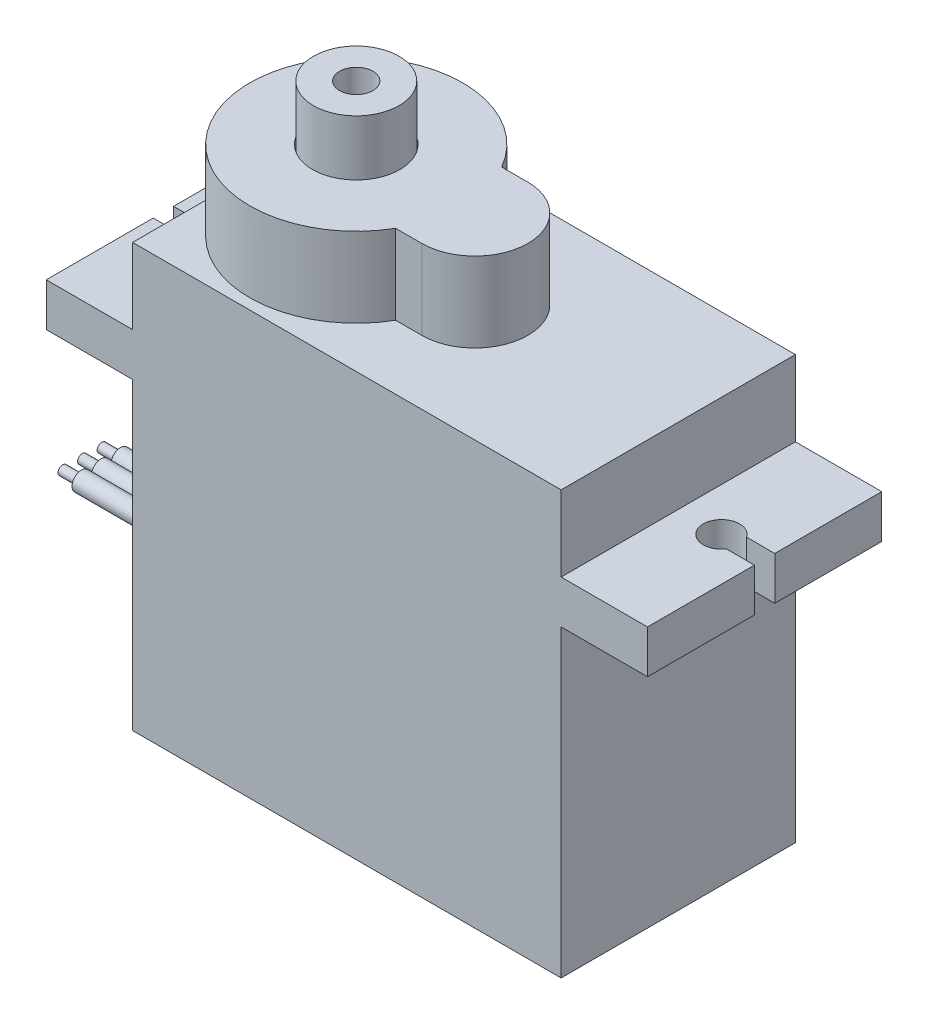
from build123d import *

# Parameters (mm, degrees)
BOSS_EXTRUDE1_DEPTH      = 6.295
BOSS_EXTRUDE2_DEPTH      = 4.28
SKETCH4_R                = 0.975
SKETCH4_W                = 1.511544683
SKETCH4_H                = 1.09
CUT_EXTRUDE1_DEPTH       = 27.991002668
SKETCH5_R                = 1
SKETCH5_R_2              = 0.975
CUT_EXTRUDE2_DEPTH       = 1
SKETCH6_R                = 0.5
BOSS_EXTRUDE4_DEPTH      = 8
SKETCH7_R                = 0.25
BOSS_EXTRUDE5_DEPTH      = 1
FILLET1_R                = 0.3
BOSS_EXTRUDE6_DEPTH      = 2.95
BOSS_EXTRUDE6_DEPTH_BACK = 1
SKETCH12_R               = 2.3
SKETCH12_R_2             = 0.9
SKETCH13_R               = 2.35
CUT_EXTRUDE5_DEPTH       = 5


with BuildPart() as part:
    # Sketch1 → Boss-Extrude1 (new, symmetric)
    with BuildSketch(Plane.XY):
        Polygon((-7.13, 6.38), (15.9, 6.38), (15.9, 2.32), (20.54, 2.32), (20.54, 0), (15.9, 0), (15.9, -16.34), (-7.13, -16.34), (-7.13, 0), (-11.77, 0), (-11.77, 2.32), (-7.13, 2.32), align=None)
    extrude(amount=BOSS_EXTRUDE1_DEPTH, both=True)

    # Sketch2 → Boss-Extrude2 (add)
    with BuildSketch(Plane(origin=(0, 6.38, 0), x_dir=(1, 0, 0), z_dir=(0, 1, 0))):
        with BuildLine():
            Line((3.560191336, -2.85), (4.97, -2.85))
            ThreePointArc((4.97, -2.85), (7.82, 0), (4.97, 2.85))
            Line((4.97, 2.85), (3.560191336, 2.85))
            ThreePointArc((3.560191336, 2.85), (-7.13, 0), (3.560191336, -2.85))
        make_face()
    extrude(amount=BOSS_EXTRUDE2_DEPTH)

    # Sketch4 → Cut-Extrude1 (cut, through all)
    with BuildSketch(Plane(origin=(0, 0, 0), x_dir=(1, 0, 0), z_dir=(0, 1, 0))):
        with Locations((-9.45, 0)):
            Circle(SKETCH4_R)
        with Locations((-11.014227659, 0)):
            Rectangle(SKETCH4_W, SKETCH4_H)
    cut_extrude1 = extrude(amount=CUT_EXTRUDE1_DEPTH, mode=Mode.SUBTRACT)

    # Sketch5 → Cut-Extrude2 (cut)
    # profile 1 of 4: a face of its own
    with BuildSketch(Plane.XZ.offset(16.34)):
        with Locations((-5.49, 4.35)):
            Circle(SKETCH5_R)
        with Locations((-5.49, 4.35)):
            Circle(SKETCH5_R_2, mode=Mode.SUBTRACT)
    # profile 2 of 4: a face of its own
    with BuildSketch(Plane.XZ.offset(16.34)):
        with Locations((-5.49, -4.35)):
            Circle(SKETCH5_R)
        with Locations((-5.49, -4.35)):
            Circle(SKETCH5_R_2, mode=Mode.SUBTRACT)
    # profile 3 of 4: a face of its own
    with BuildSketch(Plane.XZ.offset(16.34)):
        with Locations((14.26, -4.35)):
            Circle(SKETCH5_R)
        with Locations((14.26, -4.35)):
            Circle(SKETCH5_R_2, mode=Mode.SUBTRACT)
    # profile 4 of 4: a face of its own
    with BuildSketch(Plane.XZ.offset(16.34)):
        with Locations((14.26, 4.35)):
            Circle(SKETCH5_R)
        with Locations((14.26, 4.35)):
            Circle(SKETCH5_R_2, mode=Mode.SUBTRACT)
    extrude(amount=-CUT_EXTRUDE2_DEPTH, mode=Mode.SUBTRACT)

    # Sketch6 → Boss-Extrude4 (add)
    with BuildSketch(Plane.ZY.offset(7.13)):
        with Locations((0, -11.34)):
            Circle(SKETCH6_R)
        with Locations((1.05, -11.34)):
            Circle(SKETCH6_R)
        with Locations((-1.05, -11.34)):
            Circle(SKETCH6_R)
    extrude(amount=BOSS_EXTRUDE4_DEPTH)

    # Sketch7 → Boss-Extrude5 (add)
    with BuildSketch(Plane.ZY.offset(15.13)):
        with Locations((0, -11.34)):
            Circle(SKETCH7_R)
        with Locations((1.05, -11.34)):
            Circle(SKETCH7_R)
        with Locations((-1.05, -11.34)):
            Circle(SKETCH7_R)
    extrude(amount=BOSS_EXTRUDE5_DEPTH)

    # Fillet1
    fillet1_edges = [part.edges().sort_by_distance(p)[0] for p in [
        (13.285, -16.34, -4.35),
        (13.285, -16.34, 4.35),
        (-6.465, -16.34, -4.35),
        (-6.465, -16.34, 4.35),
    ]]
    fillet(fillet1_edges, radius=FILLET1_R)

    # Sketch13 → Cut-Extrude5 (cut)
    with BuildSketch(Plane(origin=(0, 13.61, 0), x_dir=(1, 0, 0), z_dir=(0, 1, 0))):
        with Locations((-1.405, 0)):
            Circle(SKETCH13_R)
    extrude(amount=-CUT_EXTRUDE5_DEPTH, mode=Mode.SUBTRACT)

    # Symétrie1: Cut-Extrude1 across plane
    add(cut_extrude1.mirror(Plane.ZY.offset(-4.385)), mode=Mode.SUBTRACT)


with BuildPart() as body_2:
    # Sketch12 → Boss-Extrude6 (new, two sides: drawn at the far end of the back side and taken through both)
    with BuildSketch(Plane(origin=(0, 10.66, 0), x_dir=(1, 0, 0), z_dir=(0, 1, 0)).offset(-BOSS_EXTRUDE6_DEPTH_BACK)):
        with Locations((-1.405, 0)):
            Circle(SKETCH12_R)
        with Locations((-1.405, 0)):
            Circle(SKETCH12_R_2, mode=Mode.SUBTRACT)
    extrude(amount=BOSS_EXTRUDE6_DEPTH + BOSS_EXTRUDE6_DEPTH_BACK)


solid = Compound([part.part, body_2.part])
